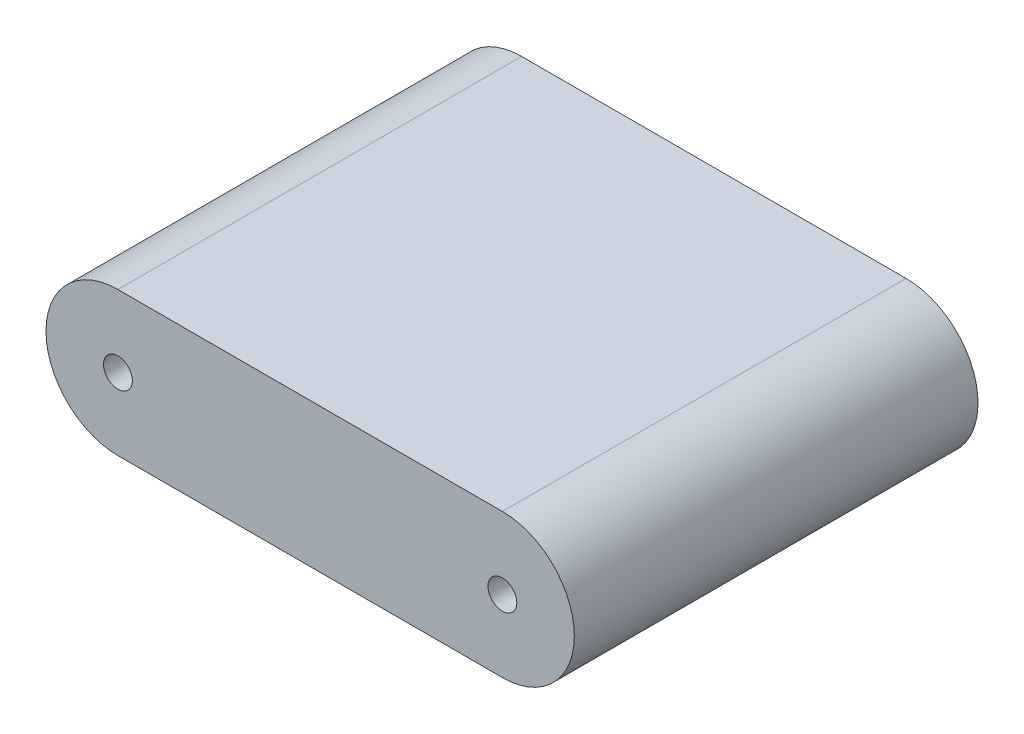
from build123d import *

# Parameters (mm, degrees)
SKETCH1_R           = 1.5
BOSS_EXTRUDE1_DEPTH = 42


with BuildPart() as part:
    # Sketch1 → Boss-Extrude1 (new body)
    with BuildSketch(Plane.XY):
        with BuildLine():
            Line((-20, 7.483273932), (20, 7.483273932))
            ThreePointArc((20, 7.483273932), (27.483273932, 0), (20, -7.483273932))
            Line((20, -7.483273932), (-20, -7.483273932))
            ThreePointArc((-20, -7.483273932), (-27.483273932, 0), (-20, 7.483273932))
        make_face()
        with Locations((20, 0)):
            Circle(SKETCH1_R, mode=Mode.SUBTRACT)
        with Locations((-20, 0)):
            Circle(SKETCH1_R, mode=Mode.SUBTRACT)
    extrude(amount=BOSS_EXTRUDE1_DEPTH)


solid = part.part
